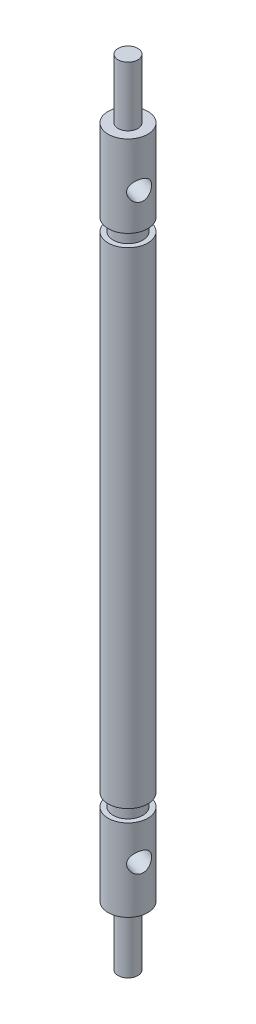
from build123d import *

# Parameters (mm, degrees)
F_2_0MM_PRESS_DOWEL_HOLE1_D = 2.005


with BuildPart() as part:
    # Sketch1 → Revolve1 (revolve)
    with BuildSketch(Plane(origin=(0, 0, 0), x_dir=(0, 0, -1), z_dir=(1, 0, 0))):
        Polygon((-1, 20), (0, 20), (0, 14), (1, 14), (1, 5.75), (0.5, 5.75), (0.5, 4.5), (1, 4.5), (1, -20), (-1, -20), align=None)
    revolve1 = revolve(axis=Axis((0, 20, 1), (0, -1, 0)))

    # Ø2.0mm Press Dowel Hole1 (through all)
    with Locations(Plane(origin=(1.903998662, 9.34, 1.612200209), x_dir=(-0.306100105, 0, 0.951999331), z_dir=(0.951999331, 0, 0.306100105))):
        with Locations((0, 0)):
            f_2_0mm_press_dowel_hole1 = Hole(F_2_0MM_PRESS_DOWEL_HOLE1_D / 2)

    # Mirror1: Revolve1, Ø2.0mm Press Dowel Hole1 across plane
    add(revolve1.mirror(Plane(origin=(0, -20, 1), x_dir=(0, 0, 1), z_dir=(0, 1, 0))))
    add(f_2_0mm_press_dowel_hole1.mirror(Plane(origin=(0, -20, 1), x_dir=(0, 0, 1), z_dir=(0, 1, 0))), mode=Mode.SUBTRACT)


solid = part.part
